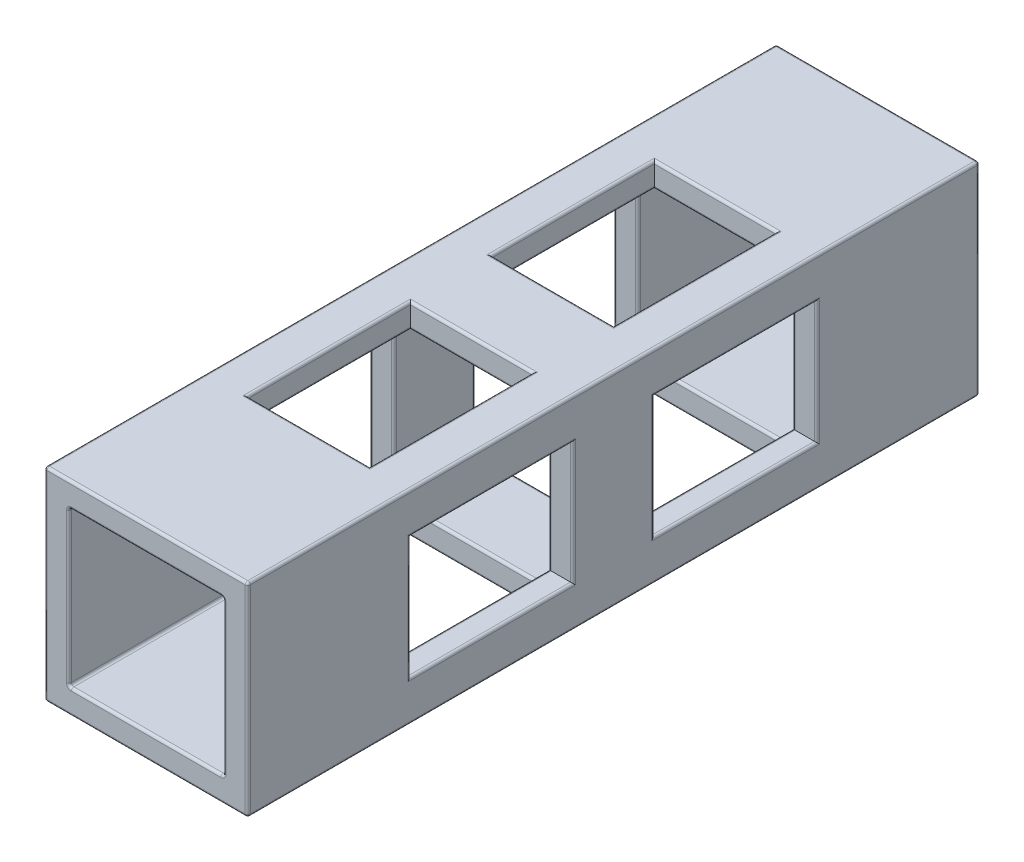
from build123d import *

# Parameters (mm, degrees)
SKETCH1_W           = 31.75
SKETCH1_H           = 31.75
BOSS_EXTRUDE1_DEPTH = 114.3
SKETCH3_W           = 24.13
SKETCH3_H           = 24.13
CUT_EXTRUDE1_DEPTH  = 114.3
SKETCH4_W           = 19.05
SKETCH4_H           = 25.4
CUT_EXTRUDE4_DEPTH  = 6.35
SKETCH10_W          = 25.4
SKETCH10_H          = 19.05
CUT_EXTRUDE5_DEPTH  = 6.35
SKETCH13_W          = 19.05
SKETCH13_H          = 25.4
CUT_EXTRUDE6_DEPTH  = 6.35
SKETCH14_W          = 25.4
SKETCH14_H          = 19.05
CUT_EXTRUDE7_DEPTH  = 6.35
FILLET1_64_R        = 0.396875


with BuildPart() as part:
    # Sketch1 → Boss-Extrude1 (new body)
    with BuildSketch(Plane.XY):
        with Locations((-6.389302447, 3.219010904)):
            Rectangle(SKETCH1_W, SKETCH1_H)
    extrude(amount=BOSS_EXTRUDE1_DEPTH)

    # Sketch3 → Cut-Extrude1 (cut)
    with BuildSketch(Plane.XY.offset(114.3)):
        with Locations((-6.389302447, 3.219010904)):
            Rectangle(SKETCH3_W, SKETCH3_H)
    extrude(amount=-CUT_EXTRUDE1_DEPTH, mode=Mode.SUBTRACT)

    # Sketch4 → Cut-Extrude4 (cut)
    with BuildSketch(Plane(origin=(0, 19.094010904, 0), x_dir=(1, 0, 0), z_dir=(0, 1, 0))):
        with Locations((-6.389302447, -76.2)):
            Rectangle(SKETCH4_W, SKETCH4_H)
        with Locations((-6.389302447, -38.1)):
            Rectangle(SKETCH4_W, SKETCH4_H)
    extrude(amount=-CUT_EXTRUDE4_DEPTH, mode=Mode.SUBTRACT)

    # Sketch10 → Cut-Extrude5 (cut)
    with BuildSketch(Plane(origin=(9.485697553, 0, 0), x_dir=(0, 0, -1), z_dir=(1, 0, 0))):
        with Locations((-76.2, 3.219010904)):
            Rectangle(SKETCH10_W, SKETCH10_H)
        with Locations((-38.1, 3.219010904)):
            Rectangle(SKETCH10_W, SKETCH10_H)
    extrude(amount=-CUT_EXTRUDE5_DEPTH, mode=Mode.SUBTRACT)

    # Sketch13 → Cut-Extrude6 (cut)
    with BuildSketch(Plane.XZ.offset(12.655989096)):
        with Locations((-6.389302447, 76.2)):
            Rectangle(SKETCH13_W, SKETCH13_H)
        with Locations((-6.389302447, 38.1)):
            Rectangle(SKETCH13_W, SKETCH13_H)
    extrude(amount=-CUT_EXTRUDE6_DEPTH, mode=Mode.SUBTRACT)

    # Sketch14 → Cut-Extrude7 (cut)
    with BuildSketch(Plane.ZY.offset(22.264302447)):
        with Locations((76.2, 3.219010904)):
            Rectangle(SKETCH14_W, SKETCH14_H)
        with Locations((38.1, 3.219010904)):
            Rectangle(SKETCH14_W, SKETCH14_H)
    extrude(amount=-CUT_EXTRUDE7_DEPTH, mode=Mode.SUBTRACT)

    # Fillet1/64
    fillet1_64_edges = [part.edges().sort_by_distance(p)[0] for p in [
        (-15.914302447, -8.845989096, 38.1),
        (-6.389302447, -8.845989096, 25.4),
        (3.135697553, -8.845989096, 38.1),
        (-6.389302447, -8.845989096, 50.8),
        (-6.389302447, -8.845989096, 63.5),
        (3.135697553, -8.845989096, 76.2),
        (-6.389302447, -8.845989096, 88.9),
        (-15.914302447, -8.845989096, 76.2),
        (-15.914302447, -12.655989096, 76.2),
        (-6.389302447, -12.655989096, 63.5),
        (3.135697553, -12.655989096, 76.2),
        (-6.389302447, -12.655989096, 88.9),
        (9.485697553, 3.219010904, 114.3),
        (-6.389302447, -12.655989096, 50.8),
        (-15.914302447, -12.655989096, 38.1),
        (-6.389302447, -12.655989096, 25.4),
        (3.135697553, -12.655989096, 38.1),
        (-18.454302447, 12.744010904, 38.1),
        (-18.454302447, 3.219010904, 25.4),
        (-18.454302447, -6.305989096, 38.1),
        (-18.454302447, 3.219010904, 50.8),
        (-18.454302447, 3.219010904, 63.5),
        (-18.454302447, -6.305989096, 76.2),
        (-18.454302447, 3.219010904, 88.9),
        (-18.454302447, 12.744010904, 76.2),
        (-22.264302447, 12.744010904, 76.2),
        (-22.264302447, 3.219010904, 63.5),
        (-22.264302447, -6.305989096, 76.2),
        (-22.264302447, 3.219010904, 88.9),
        (-6.389302447, 19.094010904, 114.3),
        (-22.264302447, 3.219010904, 50.8),
        (-22.264302447, 12.744010904, 38.1),
        (-22.264302447, 3.219010904, 25.4),
        (-22.264302447, -6.305989096, 38.1),
        (-6.389302447, -8.845989096, 0),
        (5.675697553, -8.845989096, 57.15),
        (-18.454302447, 3.219010904, 0),
        (-18.454302447, -8.845989096, 57.15),
        (-6.389302447, 15.284010904, 114.3),
        (-18.454302447, 15.284010904, 57.15),
        (5.675697553, 3.219010904, 114.3),
        (5.675697553, 15.284010904, 57.15),
        (-6.389302447, 15.284010904, 0),
        (5.675697553, 3.219010904, 0),
        (-6.389302447, -8.845989096, 114.3),
        (-18.454302447, 3.219010904, 114.3),
        (-6.389302447, 15.284010904, 50.8),
        (3.135697553, 15.284010904, 38.1),
        (-6.389302447, 15.284010904, 25.4),
        (-15.914302447, 15.284010904, 38.1),
        (3.135697553, 15.284010904, 76.2),
        (-6.389302447, 15.284010904, 63.5),
        (-15.914302447, 15.284010904, 76.2),
        (-6.389302447, 15.284010904, 88.9),
        (-15.914302447, 19.094010904, 76.2),
        (-6.389302447, 19.094010904, 63.5),
        (-6.389302447, 19.094010904, 88.9),
        (3.135697553, 19.094010904, 76.2),
        (-6.389302447, 19.094010904, 25.4),
        (3.135697553, 19.094010904, 38.1),
        (-15.914302447, 19.094010904, 38.1),
        (-6.389302447, 19.094010904, 50.8),
        (-22.264302447, 3.219010904, 114.3),
        (-6.389302447, 19.094010904, 0),
        (9.485697553, 3.219010904, 0),
        (-6.389302447, -12.655989096, 0),
        (-22.264302447, 3.219010904, 0),
        (5.675697553, 12.744010904, 38.1),
        (5.675697553, 3.219010904, 50.8),
        (5.675697553, -6.305989096, 38.1),
        (5.675697553, 3.219010904, 25.4),
        (5.675697553, -6.305989096, 76.2),
        (5.675697553, 3.219010904, 63.5),
        (5.675697553, 12.744010904, 76.2),
        (5.675697553, 3.219010904, 88.9),
        (-22.264302447, 19.094010904, 57.15),
        (9.485697553, 12.744010904, 76.2),
        (9.485697553, 19.094010904, 57.15),
        (9.485697553, 3.219010904, 63.5),
        (9.485697553, -12.655989096, 57.15),
        (9.485697553, 3.219010904, 88.9),
        (9.485697553, -6.305989096, 76.2),
        (-22.264302447, -12.655989096, 57.15),
        (9.485697553, 3.219010904, 25.4),
        (9.485697553, -6.305989096, 38.1),
        (-6.389302447, -12.655989096, 114.3),
        (9.485697553, 12.744010904, 38.1),
        (9.485697553, 3.219010904, 50.8),
    ]]
    fillet(fillet1_64_edges, radius=FILLET1_64_R)


solid = part.part
